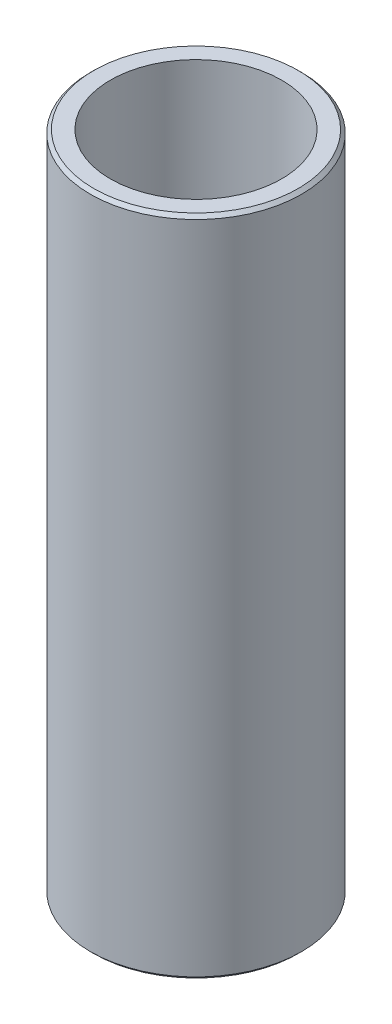
from build123d import *

# Parameters (mm, degrees)
SKETCH1_R           = 7.94
SKETCH1_R_2         = 6.44
BOSS_EXTRUDE1_DEPTH = 49.82
CHAMFER1_SIZE       = 0.25


with BuildPart() as part:
    # Sketch1 → Boss-Extrude1 (new body)
    with BuildSketch(Plane(origin=(0, 0, 0), x_dir=(1, 0, 0), z_dir=(0, 1, 0))):
        Circle(SKETCH1_R)
        Circle(SKETCH1_R_2, mode=Mode.SUBTRACT)
    extrude(amount=BOSS_EXTRUDE1_DEPTH)

    # Chamfer1
    chamfer1_edges = [part.edges().sort_by_distance(p)[0] for p in [
        (-7.94, 0, 0),
        (-7.94, 49.82, 0),
    ]]
    chamfer(chamfer1_edges, length=CHAMFER1_SIZE)


solid = part.part
